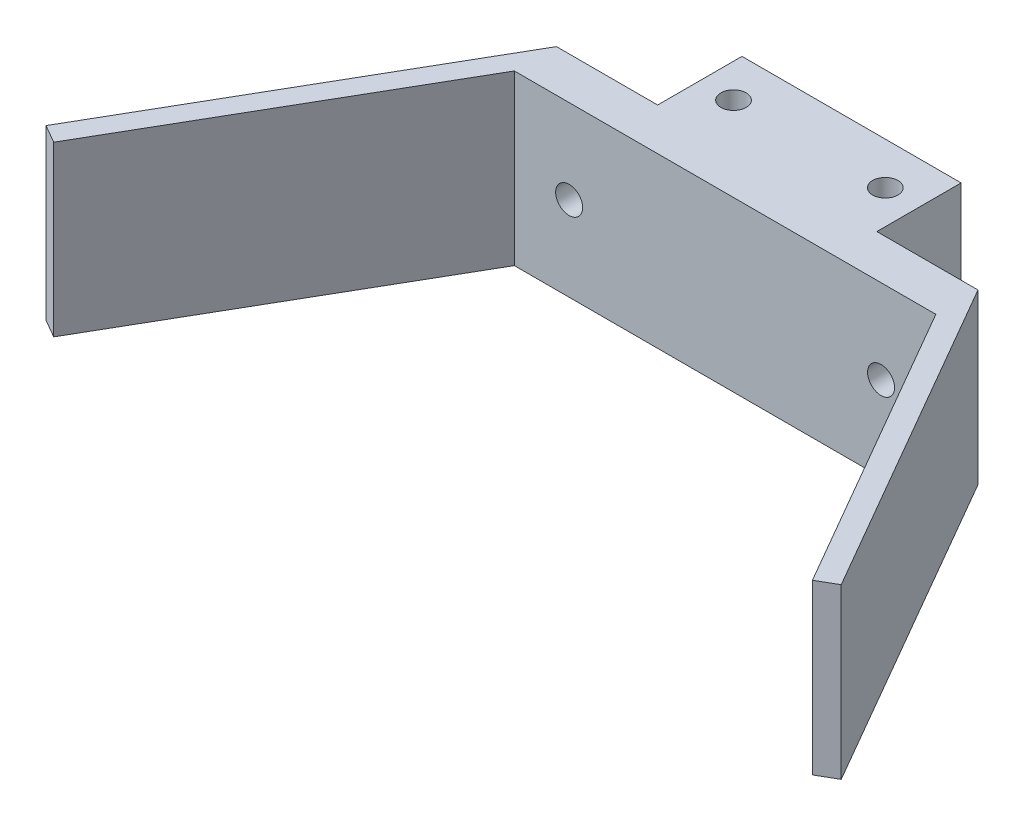
from build123d import *

# Parameters (mm, degrees)
ESQUISSE1_W        = 50
ESQUISSE1_H        = 20
ESQUISSE1_R        = 1.6
BOSS_EXTRU_1_DEPTH = 5
ESQUISSE2_W        = 26
ESQUISSE2_H        = 10
ESQUISSE2_R        = 1.5
BOSS_EXTRU_2_DEPTH = 20


with BuildPart() as part:
    # Esquisse1 → Boss.-Extru.1 (new body)
    with BuildSketch(Plane.XY):
        Rectangle(ESQUISSE1_W, ESQUISSE1_H)
        with Locations((-18.5, 0)):
            Circle(ESQUISSE1_R, mode=Mode.SUBTRACT)
        with Locations((18.5, 0)):
            Circle(ESQUISSE1_R, mode=Mode.SUBTRACT)
    extrude(amount=BOSS_EXTRU_1_DEPTH)

    # Esquisse2 → Boss.-Extru.2 (add)
    with BuildSketch(Plane(origin=(0, 10, 0), x_dir=(1, 0, 0), z_dir=(0, 1, 0))):
        Polygon((25, 0), (25, -5), (45, -39.641016151), (47.165063509, -38.391016151), align=None)
        Polygon((-45, -39.641016151), (-47.165063509, -38.391016151), (-25, 0), (-25, -5), align=None)
        with Locations((0, 5)):
            Rectangle(ESQUISSE2_W, ESQUISSE2_H)
        with Locations((-9, 5)):
            Circle(ESQUISSE2_R, mode=Mode.SUBTRACT)
        with Locations((9, 5)):
            Circle(ESQUISSE2_R, mode=Mode.SUBTRACT)
    extrude(amount=-BOSS_EXTRU_2_DEPTH)


solid = part.part
